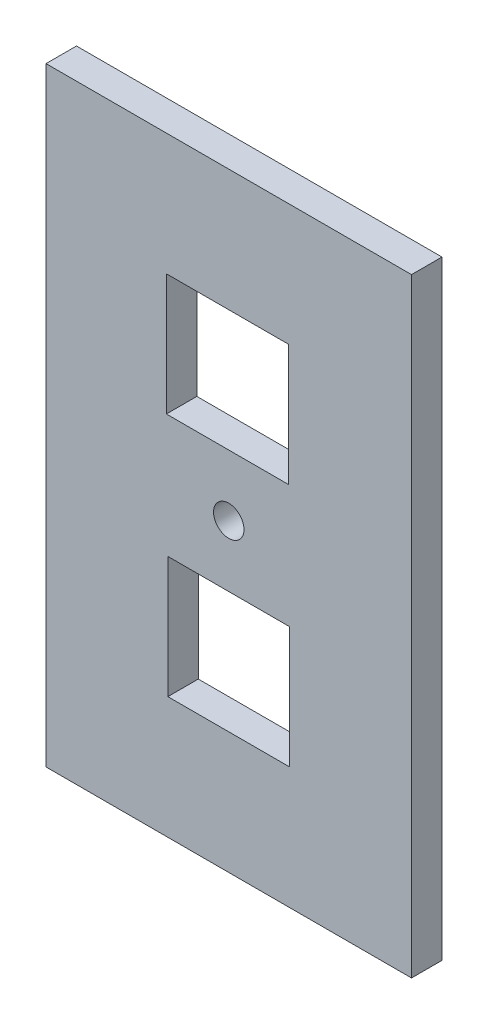
from build123d import *

# Parameters (mm, degrees)
SKETCH1_W           = 76.2
SKETCH1_H           = 127
BOSS_EXTRUDE1_DEPTH = 6.35
SKETCH3_R           = 3.175
SKETCH3_W           = 25.493937525
SKETCH3_H           = 25.320509378
SKETCH3_W_2         = 25.4
CUT_EXTRUDE2_DEPTH  = 6.35


with BuildPart() as part:
    # Sketch1 → Boss-Extrude1 (new body)
    with BuildSketch(Plane.XY):
        with Locations((38.1, 63.5)):
            Rectangle(SKETCH1_W, SKETCH1_H)
    extrude(amount=BOSS_EXTRUDE1_DEPTH)

    # Sketch3 → Cut-Extrude2 (cut)
    with BuildSketch(Plane.XY.offset(6.35)):
        with Locations((38.1, 63.5)):
            Circle(SKETCH3_R)
        with Locations((37.83985778, 88.939745311)):
            Rectangle(SKETCH3_W, SKETCH3_H)
        with Locations((38.1, 38.060254689)):
            Rectangle(SKETCH3_W_2, SKETCH3_H)
    extrude(amount=-CUT_EXTRUDE2_DEPTH, mode=Mode.SUBTRACT)


solid = part.part
